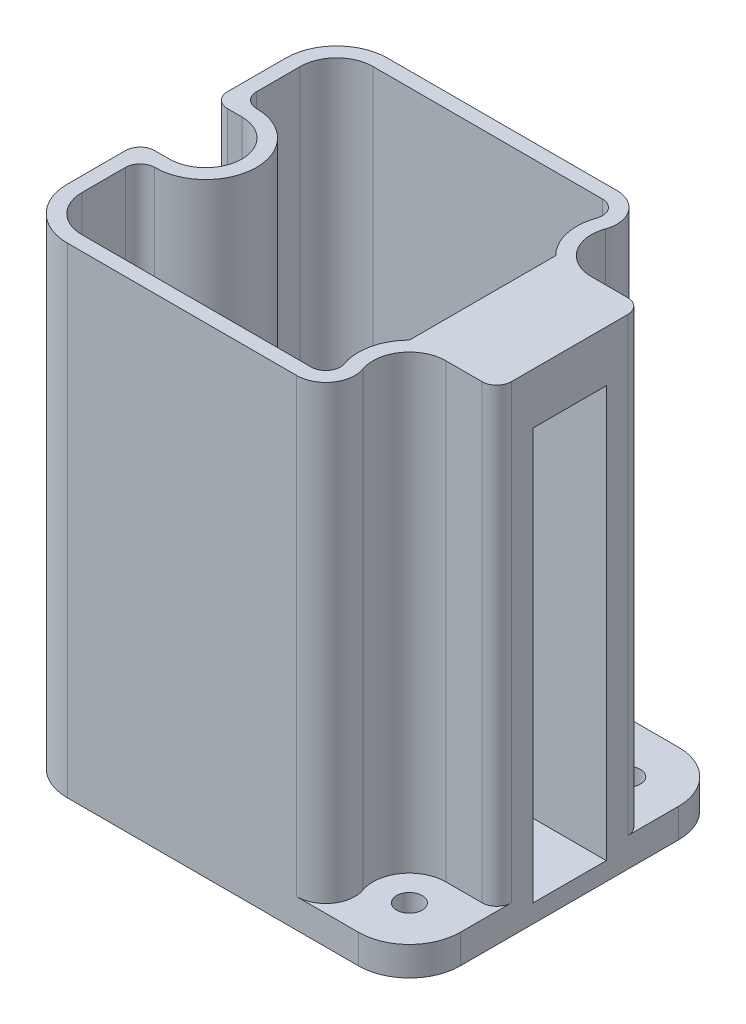
from build123d import *

# Parameters (mm, degrees)
CROQUIS1_R              = 1.75
SALIENTE_EXTRUIR1_DEPTH = 2
CROQUIS2_R              = 1.75
SALIENTE_EXTRUIR2_DEPTH = 64
CORTAR_EXTRUIR1_DEPTH   = 62
REDONDEO1_R             = 2
CORTAR_EXTRUIR2_REACH   = 56
CROQUIS5_W              = 10.1
CROQUIS5_H              = 56.5


with BuildPart() as part:
    # Croquis1 → Saliente-Extruir1 (new body)
    with BuildSketch(Plane(origin=(0, 89.4998128, 0), x_dir=(1, 0, 0), z_dir=(0, 1, 0))):
        with BuildLine():
            Line((-45.118250968, 6.084971867), (-5.118250968, 6.084971867))
            ThreePointArc((-5.118250968, 6.084971867), (-0.1685035, 8.135224399), (1.881749032, 13.084971867))
            Line((1.881749032, 13.084971867), (1.881749032, 43.084971867))
            ThreePointArc((1.881749032, 43.084971867), (-0.1685035, 48.034719335), (-5.118250968, 50.084971867))
            Line((-5.118250968, 50.084971867), (-45.118250968, 50.084971867))
            ThreePointArc((-45.118250968, 50.084971867), (-50.067998436, 48.034719335), (-52.118250968, 43.084971867))
            Line((-52.118250968, 43.084971867), (-52.118250968, 13.084971867))
            ThreePointArc((-52.118250968, 13.084971867), (-50.067998436, 8.135224399), (-45.118250968, 6.084971867))
        make_face()
        with Locations((-48.118250968, 28.084971867)):
            Circle(CROQUIS1_R, mode=Mode.SUBTRACT)
        with Locations((-5.118250968, 43.084971867)):
            Circle(CROQUIS1_R, mode=Mode.SUBTRACT)
        with Locations((-5.118250968, 13.084971867)):
            Circle(CROQUIS1_R, mode=Mode.SUBTRACT)
        with BuildLine():
            Line((-45.118250968, 8.084971867), (-13.603532342, 8.084971867))
            ThreePointArc((-13.603532342, 8.084971867), (-11.97053918, 8.930271329), (-11.717914259, 10.751638534))
            ThreePointArc((-11.717914259, 10.751638534), (-11.945259003, 14.631568546), (-10.067998436, 18.034719335))
            Line((-10.067998436, 18.034719335), (-10.067998436, 38.135224399))
            ThreePointArc((-10.067998436, 38.135224399), (-11.945259003, 41.538375188), (-11.717914259, 45.4183052))
            ThreePointArc((-11.717914259, 45.4183052), (-11.97053918, 47.239672405), (-13.603532342, 48.084971867))
            Line((-13.603532342, 48.084971867), (-45.118250968, 48.084971867))
            ThreePointArc((-45.118250968, 48.084971867), (-48.653784874, 46.620505773), (-50.118250968, 43.084971867))
            Line((-50.118250968, 43.084971867), (-50.118250968, 37.084971867))
            ThreePointArc((-50.118250968, 37.084971867), (-49.53246453, 35.670758305), (-48.118250968, 35.084971867))
            ThreePointArc((-48.118250968, 35.084971867), (-41.118250968, 28.084971867), (-48.118250968, 21.084971867))
            ThreePointArc((-48.118250968, 21.084971867), (-49.53246453, 20.499185429), (-50.118250968, 19.084971867))
            Line((-50.118250968, 19.084971867), (-50.118250968, 13.084971867))
            ThreePointArc((-50.118250968, 13.084971867), (-48.653784874, 9.549437961), (-45.118250968, 8.084971867))
        make_face(mode=Mode.SUBTRACT)
    extrude(amount=SALIENTE_EXTRUIR1_DEPTH)

    # Croquis2 → Saliente-Extruir2 (add)
    with BuildSketch(Plane(origin=(0, 91.4998128, 0), x_dir=(1, 0, 0), z_dir=(0, 1, 0))):
        with BuildLine():
            Line((-45.118250968, 6.084971867), (-5.118250968, 6.084971867))
            ThreePointArc((-5.118250968, 6.084971867), (-0.1685035, 8.135224399), (1.881749032, 13.084971867))
            Line((1.881749032, 13.084971867), (1.881749032, 43.084971867))
            ThreePointArc((1.881749032, 43.084971867), (-0.1685035, 48.034719335), (-5.118250968, 50.084971867))
            Line((-5.118250968, 50.084971867), (-45.118250968, 50.084971867))
            ThreePointArc((-45.118250968, 50.084971867), (-50.067998436, 48.034719335), (-52.118250968, 43.084971867))
            Line((-52.118250968, 43.084971867), (-52.118250968, 13.084971867))
            ThreePointArc((-52.118250968, 13.084971867), (-50.067998436, 8.135224399), (-45.118250968, 6.084971867))
        make_face()
        with Locations((-48.118250968, 28.084971867)):
            Circle(CROQUIS2_R, mode=Mode.SUBTRACT)
        with Locations((-5.118250968, 43.084971867)):
            Circle(CROQUIS2_R, mode=Mode.SUBTRACT)
        with Locations((-5.118250968, 13.084971867)):
            Circle(CROQUIS2_R, mode=Mode.SUBTRACT)
        with BuildLine():
            Line((-10.067998436, 18.034719335), (-10.067998436, 38.135224399))
            ThreePointArc((-10.067998436, 38.135224399), (-11.945259003, 41.538375188), (-11.717914259, 45.4183052))
            ThreePointArc((-11.717914259, 45.4183052), (-11.97053918, 47.239672405), (-13.603532342, 48.084971867))
            Line((-13.603532342, 48.084971867), (-45.118250968, 48.084971867))
            ThreePointArc((-45.118250968, 48.084971867), (-48.653784874, 46.620505773), (-50.118250968, 43.084971867))
            Line((-50.118250968, 43.084971867), (-50.118250968, 37.084971867))
            ThreePointArc((-50.118250968, 37.084971867), (-49.53246453, 35.670758305), (-48.118250968, 35.084971867))
            ThreePointArc((-48.118250968, 35.084971867), (-41.118250968, 28.084971867), (-48.118250968, 21.084971867))
            ThreePointArc((-48.118250968, 21.084971867), (-49.53246453, 20.499185429), (-50.118250968, 19.084971867))
            Line((-50.118250968, 19.084971867), (-50.118250968, 13.084971867))
            ThreePointArc((-50.118250968, 13.084971867), (-48.653784874, 9.549437961), (-45.118250968, 8.084971867))
            Line((-45.118250968, 8.084971867), (-13.603532342, 8.084971867))
            ThreePointArc((-13.603532342, 8.084971867), (-11.97053918, 8.930271329), (-11.717914259, 10.751638534))
            ThreePointArc((-11.717914259, 10.751638534), (-11.945259003, 14.631568546), (-10.067998436, 18.034719335))
        make_face(mode=Mode.SUBTRACT)
    extrude(amount=SALIENTE_EXTRUIR2_DEPTH)

    # Croquis3 → Cortar-Extruir1 (cut)
    with BuildSketch(Plane(origin=(0, 155.4998128, 0), x_dir=(1, 0, 0), z_dir=(0, 1, 0))):
        with BuildLine():
            Line((-5.118250968, 38.084971867), (1.881749032, 38.084971867))
            Line((1.881749032, 38.084971867), (1.881749032, 43.084971867))
            ThreePointArc((1.881749032, 43.084971867), (-0.1685035, 48.034719335), (-5.118250968, 50.084971867))
            Line((-5.118250968, 50.084971867), (-13.603532342, 50.084971867))
            ThreePointArc((-13.603532342, 50.084971867), (-10.337546018, 48.394372944), (-9.832296176, 44.751638534))
            ThreePointArc((-9.832296176, 44.751638534), (-9.994685279, 41.980259953), (-8.653784874, 39.549437961))
            ThreePointArc((-8.653784874, 39.549437961), (-7.03166813, 38.465574204), (-5.118250968, 38.084971867))
        make_face()
        with BuildLine():
            Line((-5.118250968, 18.084971867), (1.881749032, 18.084971867))
            Line((1.881749032, 18.084971867), (1.881749032, 13.084971867))
            ThreePointArc((1.881749032, 13.084971867), (-0.1685035, 8.135224399), (-5.118250968, 6.084971867))
            Line((-5.118250968, 6.084971867), (-13.603532342, 6.084971867))
            ThreePointArc((-13.603532342, 6.084971867), (-10.337546018, 7.77557079), (-9.832296176, 11.4183052))
            ThreePointArc((-9.832296176, 11.4183052), (-9.994685279, 14.18968378), (-8.653784874, 16.620505773))
            ThreePointArc((-8.653784874, 16.620505773), (-7.03166813, 17.704369529), (-5.118250968, 18.084971867))
        make_face()
        with BuildLine():
            Line((-48.118250968, 23.084971867), (-52.118250968, 23.084971867))
            Line((-52.118250968, 23.084971867), (-52.118250968, 33.084971867))
            Line((-52.118250968, 33.084971867), (-48.118250968, 33.084971867))
            ThreePointArc((-48.118250968, 33.084971867), (-43.118250968, 28.084971867), (-48.118250968, 23.084971867))
        make_face()
    extrude(amount=-CORTAR_EXTRUIR1_DEPTH, mode=Mode.SUBTRACT)

    # Redondeo1
    redondeo1_edges = [part.edges().sort_by_distance(p)[0] for p in [
        (1.881749032, 124.4998128, -18.084971867),
        (1.881749032, 124.4998128, -38.084971867),
        (-52.118250968, 124.4998128, -23.084971867),
        (-52.118250968, 124.4998128, -33.084971867),
    ]]
    fillet(redondeo1_edges, radius=REDONDEO1_R)

    # Croquis5 → Cortar-Extruir2 (cut, up to next)
    with BuildSketch(Plane(origin=(1.881749032, 0, 0), x_dir=(0, 0, -1), z_dir=(1, 0, 0)), mode=Mode.PRIVATE) as cortar_extruir2_sk1:
        with Locations((28.084971867, 120.2498128)):
            Rectangle(CROQUIS5_W, CROQUIS5_H)
    cortar_extruir2_tool1 = extrude(cortar_extruir2_sk1.sketch, amount=-CORTAR_EXTRUIR2_REACH, mode=Mode.PRIVATE) & part.part
    add(cortar_extruir2_tool1.solids().sort_by_distance((1.881749, 120.249813, -28.084972))[0], mode=Mode.SUBTRACT)


solid = part.part
